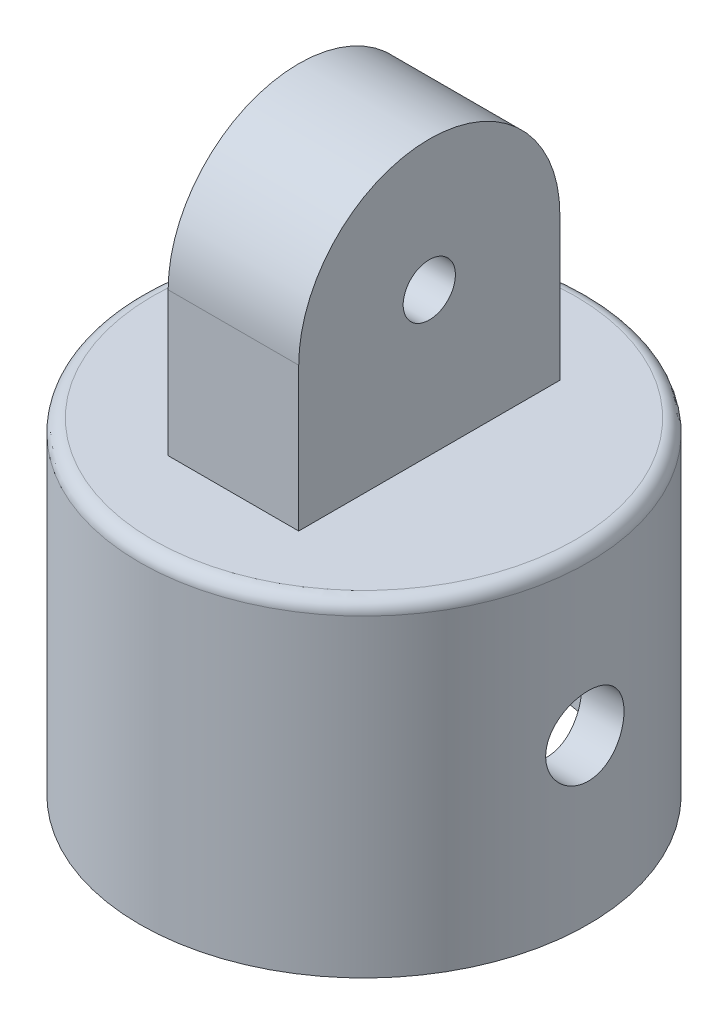
from build123d import *

# Parameters (mm, degrees)
SKETCH1_R               = 17.175
BOSS_EXTRUDE2_DEPTH     = 25
SHELL1_T                = -3.175
SKETCH3_R               = 3
CUT_EXTRUDE1_DEPTH      = 35.856294267
CUT_EXTRUDE1_DEPTH_BACK = 35.856294267
SKETCH5_R               = 2
BOSS_EXTRUDE3_DEPTH     = 5
FILLET1_R               = 1


with BuildPart() as part:
    # Sketch1 → Boss-Extrude2 (new body)
    with BuildSketch(Plane(origin=(0, 0, 0), x_dir=(1, 0, 0), z_dir=(0, 1, 0))):
        with Locations(Location((0, 0, 0), (0, 0, 270))):
            Circle(SKETCH1_R)
    extrude(amount=BOSS_EXTRUDE2_DEPTH)

    # Shell1
    shell1_openings = [part.faces().sort_by_distance(p)[0] for p in [
        (0, 0, 0),
    ]]
    offset(amount=SHELL1_T, openings=shell1_openings, kind=Kind.INTERSECTION)

    # Sketch3 → Cut-Extrude1 (cut, two sides)
    with BuildSketch(Plane(origin=(0, 0, 0), x_dir=(0, 0, -1), z_dir=(1, 0, 0))) as cut_extrude1_sk:
        with Locations((0, 12.5)):
            Circle(SKETCH3_R)
    extrude(amount=CUT_EXTRUDE1_DEPTH, mode=Mode.SUBTRACT)
    extrude(cut_extrude1_sk.sketch, amount=-CUT_EXTRUDE1_DEPTH_BACK, mode=Mode.SUBTRACT)

    # Sketch5 → Boss-Extrude3 (add, symmetric)
    with BuildSketch(Plane(origin=(0, 0, 0), x_dir=(0, 0, -1), z_dir=(1, 0, 0))):
        with BuildLine():
            Line((-10, 36), (-10, 25))
            Line((-10, 25), (-10, 24.25))
            Line((-10, 24.25), (10, 24.25))
            Line((10, 24.25), (10, 25))
            Line((10, 25), (10, 36))
            ThreePointArc((10, 36), (0, 46), (-10, 36))
        make_face()
        with Locations((0, 36)):
            Circle(SKETCH5_R, mode=Mode.SUBTRACT)
    extrude(amount=BOSS_EXTRUDE3_DEPTH, both=True)

    # Fillet1
    fillet1_edges = [part.edges().sort_by_distance(p)[0] for p in [
        (0, 25, -17.175),
    ]]
    fillet(fillet1_edges, radius=FILLET1_R)


solid = part.part
